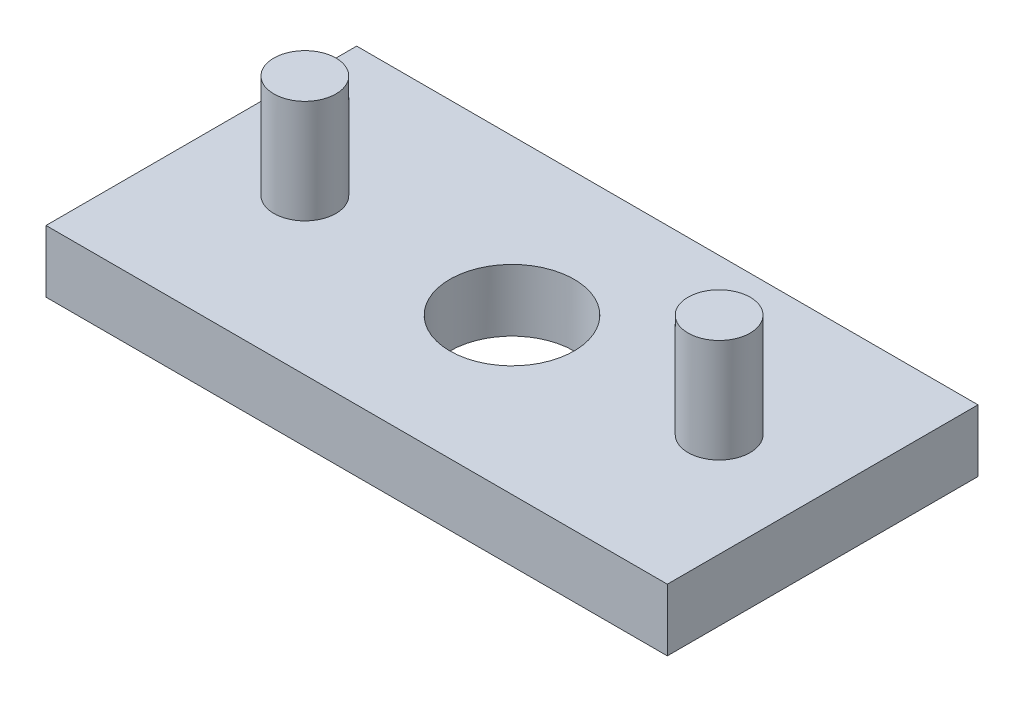
from build123d import *

# Parameters (mm, degrees)
SKETCH_1_W          = 300
SKETCH_1_H          = 150
EXTRUDE_1_DEPTH     = 30
SKETCH_2_R          = 15
EXTRUDE_2_DEPTH     = 50
SKETCH_3_R          = 30
CUT_EXTRUDE_1_DEPTH = 50


with BuildPart() as part:
    # 草图1 → 凸台-拉伸1 (new body)
    with BuildSketch(Plane(origin=(0, 0, 0), x_dir=(1, 0, 0), z_dir=(0, 1, 0))):
        Rectangle(SKETCH_1_W, SKETCH_1_H)
    extrude(amount=EXTRUDE_1_DEPTH)

    # 草图2 → 凸台-拉伸2 (add)
    with BuildSketch(Plane(origin=(0, 30, 0), x_dir=(1, 0, 0), z_dir=(0, 1, 0))):
        with Locations((-100, 0)):
            Circle(SKETCH_2_R)
        with Locations((100, 0)):
            Circle(SKETCH_2_R)
    extrude(amount=EXTRUDE_2_DEPTH)

    # 草图3 → 切除-拉伸1 (cut)
    with BuildSketch(Plane(origin=(0, 30, 0), x_dir=(1, 0, 0), z_dir=(0, 1, 0))):
        Circle(SKETCH_3_R)
    extrude(amount=-CUT_EXTRUDE_1_DEPTH, mode=Mode.SUBTRACT)


solid = part.part
